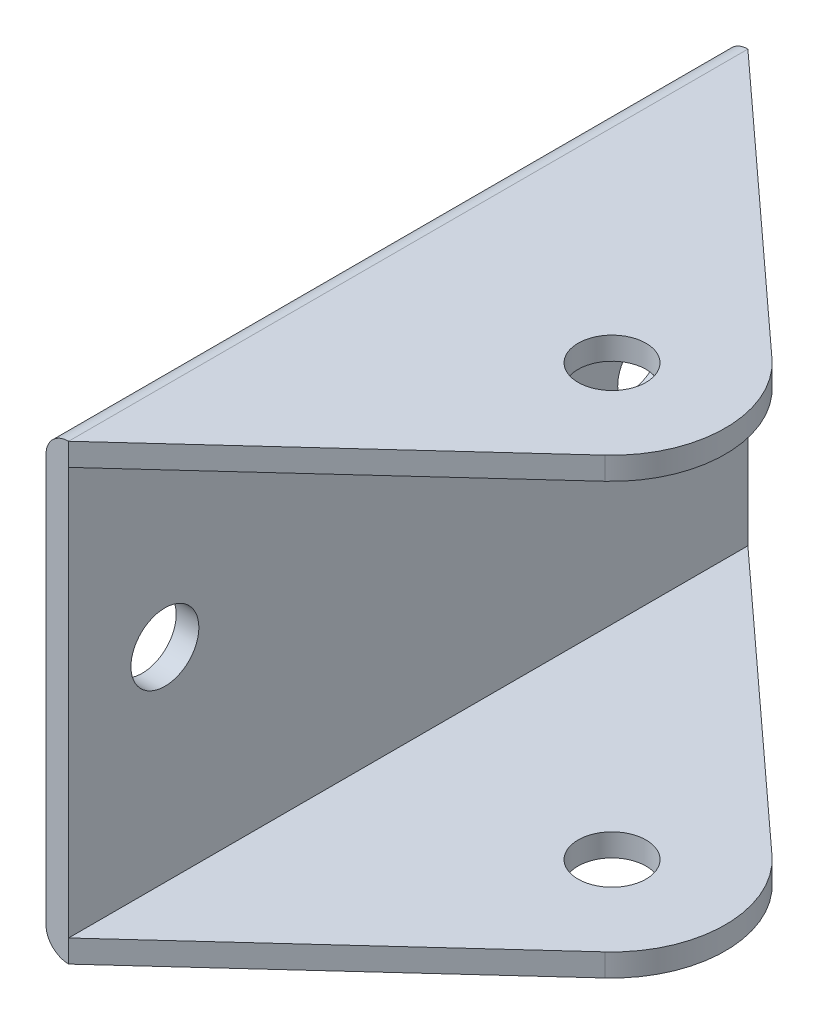
from build123d import *

# Parameters (mm, degrees)
SKETCH_1_W               = 36
SKETCH_1_H               = 36
EXTRUDE_1_DEPTH          = 100
SKETCH_2_R               = 3
CUT_EXTRUDE_1_DEPTH      = 1
CUT_EXTRUDE_1_DEPTH_BACK = 41
SKETCH_3_OUTSIDE_W       = 64.978
SKETCH_3_OUTSIDE_H       = 124.978
CUT_EXTRUDE_2_DEPTH      = 1
CUT_EXTRUDE_2_DEPTH_BACK = 41
SKETCH_4_R               = 3
CUT_EXTRUDE_3_DEPTH      = 29
CUT_EXTRUDE_3_DEPTH_BACK = 3


with BuildPart() as part:
    # Эскиз1 → Бобышка-Вытянуть1 (new body)
    with BuildSketch(Plane.XY):
        with BuildLine():
            Line((-18, 20), (18, 20))
            ThreePointArc((18, 20), (19.414213562, 19.414213562), (20, 18))
            Line((20, 18), (20, -18))
            ThreePointArc((20, -18), (19.414213562, -19.414213562), (18, -20))
            Line((18, -20), (-18, -20))
            ThreePointArc((-18, -20), (-19.414213562, -19.414213562), (-20, -18))
            Line((-20, -18), (-20, 18))
            ThreePointArc((-20, 18), (-19.414213562, 19.414213562), (-18, 20))
        make_face()
        Rectangle(SKETCH_1_W, SKETCH_1_H, mode=Mode.SUBTRACT)
    extrude(amount=EXTRUDE_1_DEPTH)

    # Эскиз2 → Вырез-Вытянуть1 (cut, two sides)
    with BuildSketch(Plane(origin=(0, 20, 0), x_dir=(1, 0, 0), z_dir=(0, 1, 0))) as cut_extrude_1_sk:
        with Locations((0, -50)):
            Circle(SKETCH_2_R)
    extrude(amount=CUT_EXTRUDE_1_DEPTH, mode=Mode.SUBTRACT)
    extrude(cut_extrude_1_sk.sketch, amount=-CUT_EXTRUDE_1_DEPTH_BACK, mode=Mode.SUBTRACT)

    # Эскиз3 outside → Вырез-Вытянуть2 (cut, two sides)
    with BuildSketch(Plane(origin=(0, 20, 0), x_dir=(1, 0, 0), z_dir=(0, 1, 0))) as cut_extrude_2_sk:
        with Locations((0, -50)):
            Rectangle(SKETCH_3_OUTSIDE_W, SKETCH_3_OUTSIDE_H)
        with BuildLine():
            Line((6.746595399, -42.618709427), (-18, -20))
            Line((-18, -20), (-21.837410107, -20))
            Line((-21.837410107, -20), (-21.837410107, -80))
            Line((-21.837410107, -80), (-18, -80))
            Line((-18, -80), (6.746595399, -57.381290573))
            ThreePointArc((6.746595399, -57.381290573), (10, -50), (6.746595399, -42.618709427))
        make_face(mode=Mode.SUBTRACT)
    extrude(amount=CUT_EXTRUDE_2_DEPTH, mode=Mode.SUBTRACT)
    extrude(cut_extrude_2_sk.sketch, amount=-CUT_EXTRUDE_2_DEPTH_BACK, mode=Mode.SUBTRACT)

    # Эскиз4 → Вырез-Вытянуть3 (cut, two sides)
    with BuildSketch(Plane(origin=(-18, 0, 0), x_dir=(0, 0, -1), z_dir=(1, 0, 0))) as cut_extrude_3_sk:
        with Locations((-71.5, 0)):
            Circle(SKETCH_4_R)
        with Locations((-28.5, 0)):
            Circle(SKETCH_4_R)
    extrude(amount=CUT_EXTRUDE_3_DEPTH, mode=Mode.SUBTRACT)
    extrude(cut_extrude_3_sk.sketch, amount=-CUT_EXTRUDE_3_DEPTH_BACK, mode=Mode.SUBTRACT)


solid = part.part
